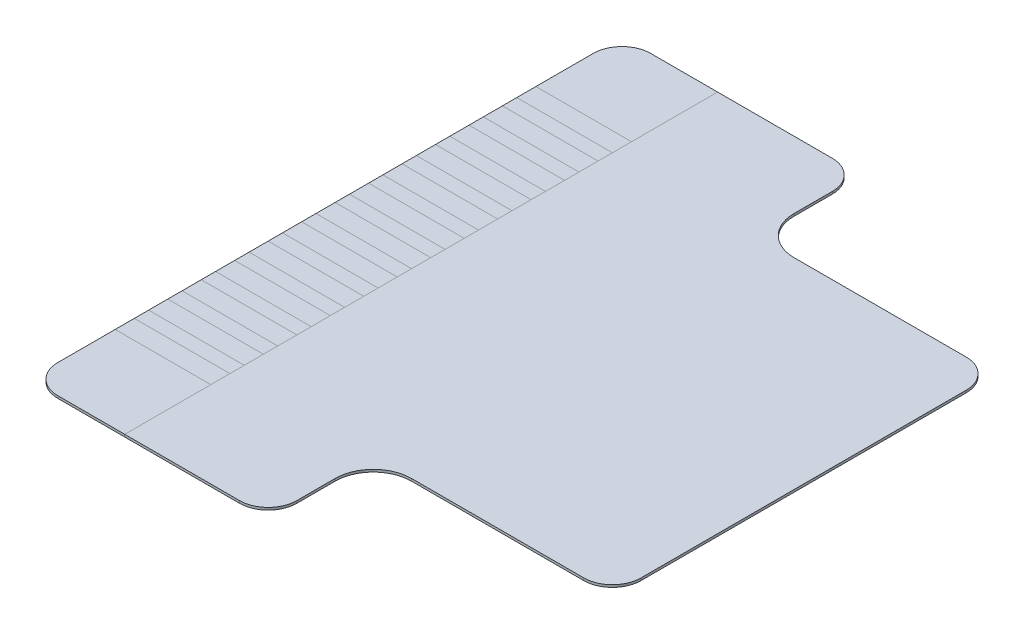
from build123d import *

# Parameters (mm, degrees)
EXTRUDE_1_DEPTH    = 0.05
SKETCH_1_3_W       = 2
SKETCH_1_3_H       = 0.4
EXTRUDE_2_DEPTH    = 0.05
EXTRUDE_2_2_DEPTH  = 0.05
EXTRUDE_2_3_DEPTH  = 0.05
EXTRUDE_2_4_DEPTH  = 0.05
EXTRUDE_2_5_DEPTH  = 0.05
EXTRUDE_2_6_DEPTH  = 0.05
EXTRUDE_2_7_DEPTH  = 0.05
EXTRUDE_2_8_DEPTH  = 0.05
EXTRUDE_2_9_DEPTH  = 0.05
EXTRUDE_2_10_DEPTH = 0.05
EXTRUDE_2_11_DEPTH = 0.05
EXTRUDE_2_12_DEPTH = 0.05
EXTRUDE_2_13_DEPTH = 0.05
SKETCH_1_5_W       = 2
SKETCH_1_5_H       = 0.3
EXTRUDE_3_DEPTH    = 0.05
EXTRUDE_3_2_DEPTH  = 0.05
EXTRUDE_3_3_DEPTH  = 0.05
EXTRUDE_3_4_DEPTH  = 0.05
EXTRUDE_3_5_DEPTH  = 0.05
EXTRUDE_3_6_DEPTH  = 0.05
EXTRUDE_3_7_DEPTH  = 0.05
EXTRUDE_3_8_DEPTH  = 0.05
EXTRUDE_3_9_DEPTH  = 0.05
EXTRUDE_3_10_DEPTH = 0.05
EXTRUDE_3_11_DEPTH = 0.05
EXTRUDE_3_12_DEPTH = 0.05
EXTRUDE_3_13_DEPTH = 0.05
EXTRUDE_3_14_DEPTH = 0.05


with BuildPart() as part:
    # 草图1 → 凸台-拉伸1 (new body)
    with BuildSketch(Plane(origin=(0, 0, 0), x_dir=(1, 0, 0), z_dir=(0, 1, 0))):
        with BuildLine():
            Line((-5.302780917, 1.2), (-5.302780917, 0.9))
            Line((-5.302780917, 0.9), (-5.302780917, 0.5))
            Line((-5.302780917, 0.5), (-5.302780917, 0.2))
            Line((-5.302780917, 0.2), (-5.302780917, -0.2))
            Line((-5.302780917, -0.2), (-5.302780917, -0.5))
            Line((-5.302780917, -0.5), (-5.302780917, -0.9))
            Line((-5.302780917, -0.9), (-5.302780917, -1.2))
            Line((-5.302780917, -1.2), (-5.302780917, -1.6))
            Line((-5.302780917, -1.6), (-5.302780917, -1.9))
            Line((-5.302780917, -1.9), (-5.302780917, -2.3))
            Line((-5.302780917, -2.3), (-5.302780917, -2.6))
            Line((-5.302780917, -2.6), (-5.302780917, -3))
            Line((-5.302780917, -3), (-5.302780917, -3.3))
            Line((-5.302780917, -3.3), (-5.302780917, -3.7))
            Line((-5.302780917, -3.7), (-5.302780917, -4))
            Line((-5.302780917, -4), (-5.302780917, -4.4))
            Line((-5.302780917, -4.4), (-5.302780917, -6.2))
            Line((-5.302780917, -6.2), (-2.902780917, -6.2))
            ThreePointArc((-2.902780917, -6.2), (-2.478516848, -6.024264069), (-2.302780917, -5.6))
            Line((-2.302780917, -5.6), (-2.302780917, -4.8))
            ThreePointArc((-2.302780917, -4.8), (-2.068466342, -4.234314575), (-1.502780917, -4))
            Line((-1.502780917, -4), (2.097219083, -4))
            ThreePointArc((2.097219083, -4), (2.521483152, -3.824264069), (2.697219083, -3.4))
            Line((2.697219083, -3.4), (2.697219083, 3.4))
            ThreePointArc((2.697219083, 3.4), (2.521483152, 3.824264069), (2.097219083, 4))
            Line((2.097219083, 4), (-1.502780917, 4))
            ThreePointArc((-1.502780917, 4), (-2.068466342, 4.234314575), (-2.302780917, 4.8))
            Line((-2.302780917, 4.8), (-2.302780917, 5.6))
            ThreePointArc((-2.302780917, 5.6), (-2.478516848, 6.024264069), (-2.902780917, 6.2))
            Line((-2.902780917, 6.2), (-5.302780917, 6.2))
            Line((-5.302780917, 6.2), (-5.302780917, 4.4))
            Line((-5.302780917, 4.4), (-5.302780917, 4))
            Line((-5.302780917, 4), (-5.302780917, 3.7))
            Line((-5.302780917, 3.7), (-5.302780917, 3.3))
            Line((-5.302780917, 3.3), (-5.302780917, 3))
            Line((-5.302780917, 3), (-5.302780917, 2.6))
            Line((-5.302780917, 2.6), (-5.302780917, 2.3))
            Line((-5.302780917, 2.3), (-5.302780917, 1.9))
            Line((-5.302780917, 1.9), (-5.302780917, 1.6))
            Line((-5.302780917, 1.6), (-5.302780917, 1.2))
        make_face()
    extrude(amount=EXTRUDE_1_DEPTH)


with BuildPart() as body_2:
    # 草图1<3> → 凸台-拉伸2 (new body)
    with BuildSketch(Plane(origin=(0, 0, 0), x_dir=(1, 0, 0), z_dir=(0, 1, 0))):
        with Locations((-6.302780917, 0.7)):
            Rectangle(SKETCH_1_3_W, SKETCH_1_3_H)
    extrude(amount=EXTRUDE_2_DEPTH)


with BuildPart() as body_3:
    # 草图1<3> → Extrude 2 2 (new body)
    with BuildSketch(Plane(origin=(0, 0, 0), x_dir=(1, 0, 0), z_dir=(0, 1, 0))):
        with Locations((-6.302780917, 1.4)):
            Rectangle(SKETCH_1_3_W, SKETCH_1_3_H)
    extrude(amount=EXTRUDE_2_2_DEPTH)


with BuildPart() as body_4:
    # 草图1<3> → Extrude 2 3 (new body)
    with BuildSketch(Plane(origin=(0, 0, 0), x_dir=(1, 0, 0), z_dir=(0, 1, 0))):
        with Locations((-6.302780917, 0)):
            Rectangle(SKETCH_1_3_W, SKETCH_1_3_H)
    extrude(amount=EXTRUDE_2_3_DEPTH)


with BuildPart() as body_5:
    # 草图1<3> → Extrude 2 4 (new body)
    with BuildSketch(Plane(origin=(0, 0, 0), x_dir=(1, 0, 0), z_dir=(0, 1, 0))):
        with Locations((-6.302780917, 2.1)):
            Rectangle(SKETCH_1_3_W, SKETCH_1_3_H)
    extrude(amount=EXTRUDE_2_4_DEPTH)


with BuildPart() as body_6:
    # 草图1<3> → Extrude 2 5 (new body)
    with BuildSketch(Plane(origin=(0, 0, 0), x_dir=(1, 0, 0), z_dir=(0, 1, 0))):
        with Locations((-6.302780917, -0.7)):
            Rectangle(SKETCH_1_3_W, SKETCH_1_3_H)
    extrude(amount=EXTRUDE_2_5_DEPTH)


with BuildPart() as body_7:
    # 草图1<3> → Extrude 2 6 (new body)
    with BuildSketch(Plane(origin=(0, 0, 0), x_dir=(1, 0, 0), z_dir=(0, 1, 0))):
        with Locations((-6.302780917, 2.8)):
            Rectangle(SKETCH_1_3_W, SKETCH_1_3_H)
    extrude(amount=EXTRUDE_2_6_DEPTH)


with BuildPart() as body_8:
    # 草图1<3> → Extrude 2 7 (new body)
    with BuildSketch(Plane(origin=(0, 0, 0), x_dir=(1, 0, 0), z_dir=(0, 1, 0))):
        with Locations((-6.302780917, -1.4)):
            Rectangle(SKETCH_1_3_W, SKETCH_1_3_H)
    extrude(amount=EXTRUDE_2_7_DEPTH)


with BuildPart() as body_9:
    # 草图1<3> → Extrude 2 8 (new body)
    with BuildSketch(Plane(origin=(0, 0, 0), x_dir=(1, 0, 0), z_dir=(0, 1, 0))):
        with Locations((-6.302780917, 3.5)):
            Rectangle(SKETCH_1_3_W, SKETCH_1_3_H)
    extrude(amount=EXTRUDE_2_8_DEPTH)


with BuildPart() as body_10:
    # 草图1<3> → Extrude 2 9 (new body)
    with BuildSketch(Plane(origin=(0, 0, 0), x_dir=(1, 0, 0), z_dir=(0, 1, 0))):
        with Locations((-6.302780917, -2.1)):
            Rectangle(SKETCH_1_3_W, SKETCH_1_3_H)
    extrude(amount=EXTRUDE_2_9_DEPTH)


with BuildPart() as body_11:
    # 草图1<3> → Extrude 2 10 (new body)
    with BuildSketch(Plane(origin=(0, 0, 0), x_dir=(1, 0, 0), z_dir=(0, 1, 0))):
        with Locations((-6.302780917, 4.2)):
            Rectangle(SKETCH_1_3_W, SKETCH_1_3_H)
    extrude(amount=EXTRUDE_2_10_DEPTH)


with BuildPart() as body_12:
    # 草图1<3> → Extrude 2 11 (new body)
    with BuildSketch(Plane(origin=(0, 0, 0), x_dir=(1, 0, 0), z_dir=(0, 1, 0))):
        with Locations((-6.302780917, -2.8)):
            Rectangle(SKETCH_1_3_W, SKETCH_1_3_H)
    extrude(amount=EXTRUDE_2_11_DEPTH)


with BuildPart() as body_13:
    # 草图1<3> → Extrude 2 12 (new body)
    with BuildSketch(Plane(origin=(0, 0, 0), x_dir=(1, 0, 0), z_dir=(0, 1, 0))):
        with Locations((-6.302780917, -3.5)):
            Rectangle(SKETCH_1_3_W, SKETCH_1_3_H)
    extrude(amount=EXTRUDE_2_12_DEPTH)


with BuildPart() as body_14:
    # 草图1<3> → Extrude 2 13 (new body)
    with BuildSketch(Plane(origin=(0, 0, 0), x_dir=(1, 0, 0), z_dir=(0, 1, 0))):
        with Locations((-6.302780917, -4.2)):
            Rectangle(SKETCH_1_3_W, SKETCH_1_3_H)
    extrude(amount=EXTRUDE_2_13_DEPTH)


with BuildPart() as body_15:
    # 草图1<5> → 凸台-拉伸3 (new body)
    with BuildSketch(Plane(origin=(0, 0, 0), x_dir=(1, 0, 0), z_dir=(0, 1, 0))):
        with Locations((-6.302780917, 1.05)):
            Rectangle(SKETCH_1_5_W, SKETCH_1_5_H)
    extrude(amount=EXTRUDE_3_DEPTH)


with BuildPart() as body_16:
    # 草图1<5> → Extrude 3 2 (new body)
    with BuildSketch(Plane(origin=(0, 0, 0), x_dir=(1, 0, 0), z_dir=(0, 1, 0))):
        with Locations((-6.302780917, 0.35)):
            Rectangle(SKETCH_1_5_W, SKETCH_1_5_H)
    extrude(amount=EXTRUDE_3_2_DEPTH)


with BuildPart() as body_17:
    # 草图1<5> → Extrude 3 3 (new body)
    with BuildSketch(Plane(origin=(0, 0, 0), x_dir=(1, 0, 0), z_dir=(0, 1, 0))):
        with Locations((-6.302780917, 1.75)):
            Rectangle(SKETCH_1_5_W, SKETCH_1_5_H)
    extrude(amount=EXTRUDE_3_3_DEPTH)


with BuildPart() as body_18:
    # 草图1<5> → Extrude 3 4 (new body)
    with BuildSketch(Plane(origin=(0, 0, 0), x_dir=(1, 0, 0), z_dir=(0, 1, 0))):
        with Locations((-6.302780917, -0.35)):
            Rectangle(SKETCH_1_5_W, SKETCH_1_5_H)
    extrude(amount=EXTRUDE_3_4_DEPTH)


with BuildPart() as body_19:
    # 草图1<5> → Extrude 3 5 (new body)
    with BuildSketch(Plane(origin=(0, 0, 0), x_dir=(1, 0, 0), z_dir=(0, 1, 0))):
        with Locations((-6.302780917, 2.45)):
            Rectangle(SKETCH_1_5_W, SKETCH_1_5_H)
    extrude(amount=EXTRUDE_3_5_DEPTH)


with BuildPart() as body_20:
    # 草图1<5> → Extrude 3 6 (new body)
    with BuildSketch(Plane(origin=(0, 0, 0), x_dir=(1, 0, 0), z_dir=(0, 1, 0))):
        with Locations((-6.302780917, -1.05)):
            Rectangle(SKETCH_1_5_W, SKETCH_1_5_H)
    extrude(amount=EXTRUDE_3_6_DEPTH)


with BuildPart() as body_21:
    # 草图1<5> → Extrude 3 7 (new body)
    with BuildSketch(Plane(origin=(0, 0, 0), x_dir=(1, 0, 0), z_dir=(0, 1, 0))):
        with Locations((-6.302780917, 3.15)):
            Rectangle(SKETCH_1_5_W, SKETCH_1_5_H)
    extrude(amount=EXTRUDE_3_7_DEPTH)


with BuildPart() as body_22:
    # 草图1<5> → Extrude 3 8 (new body)
    with BuildSketch(Plane(origin=(0, 0, 0), x_dir=(1, 0, 0), z_dir=(0, 1, 0))):
        with Locations((-6.302780917, -1.75)):
            Rectangle(SKETCH_1_5_W, SKETCH_1_5_H)
    extrude(amount=EXTRUDE_3_8_DEPTH)


with BuildPart() as body_23:
    # 草图1<5> → Extrude 3 9 (new body)
    with BuildSketch(Plane(origin=(0, 0, 0), x_dir=(1, 0, 0), z_dir=(0, 1, 0))):
        with Locations((-6.302780917, 3.85)):
            Rectangle(SKETCH_1_5_W, SKETCH_1_5_H)
    extrude(amount=EXTRUDE_3_9_DEPTH)


with BuildPart() as body_24:
    # 草图1<5> → Extrude 3 10 (new body)
    with BuildSketch(Plane(origin=(0, 0, 0), x_dir=(1, 0, 0), z_dir=(0, 1, 0))):
        with Locations((-6.302780917, -2.45)):
            Rectangle(SKETCH_1_5_W, SKETCH_1_5_H)
    extrude(amount=EXTRUDE_3_10_DEPTH)


with BuildPart() as body_25:
    # 草图1<5> → Extrude 3 11 (new body)
    with BuildSketch(Plane(origin=(0, 0, 0), x_dir=(1, 0, 0), z_dir=(0, 1, 0))):
        with BuildLine():
            Line((-7.302780917, 5.6), (-7.302780917, 4.4))
            Line((-7.302780917, 4.4), (-5.302780917, 4.4))
            Line((-5.302780917, 4.4), (-5.302780917, 6.2))
            Line((-5.302780917, 6.2), (-6.702780917, 6.2))
            ThreePointArc((-6.702780917, 6.2), (-7.127044986, 6.024264069), (-7.302780917, 5.6))
        make_face()
    extrude(amount=EXTRUDE_3_11_DEPTH)


with BuildPart() as body_26:
    # 草图1<5> → Extrude 3 12 (new body)
    with BuildSketch(Plane(origin=(0, 0, 0), x_dir=(1, 0, 0), z_dir=(0, 1, 0))):
        with Locations((-6.302780917, -3.15)):
            Rectangle(SKETCH_1_5_W, SKETCH_1_5_H)
    extrude(amount=EXTRUDE_3_12_DEPTH)


with BuildPart() as body_27:
    # 草图1<5> → Extrude 3 13 (new body)
    with BuildSketch(Plane(origin=(0, 0, 0), x_dir=(1, 0, 0), z_dir=(0, 1, 0))):
        with Locations((-6.302780917, -3.85)):
            Rectangle(SKETCH_1_5_W, SKETCH_1_5_H)
    extrude(amount=EXTRUDE_3_13_DEPTH)


with BuildPart() as body_28:
    # 草图1<5> → Extrude 3 14 (new body)
    with BuildSketch(Plane(origin=(0, 0, 0), x_dir=(1, 0, 0), z_dir=(0, 1, 0))):
        with BuildLine():
            Line((-5.302780917, -4.4), (-7.302780917, -4.4))
            Line((-7.302780917, -4.4), (-7.302780917, -5.6))
            ThreePointArc((-7.302780917, -5.6), (-7.127044986, -6.024264069), (-6.702780917, -6.2))
            Line((-6.702780917, -6.2), (-5.302780917, -6.2))
            Line((-5.302780917, -6.2), (-5.302780917, -4.4))
        make_face()
    extrude(amount=EXTRUDE_3_14_DEPTH)


solid = Compound([part.part, body_2.part, body_3.part, body_4.part, body_5.part, body_6.part, body_7.part, body_8.part, body_9.part, body_10.part, body_11.part, body_12.part, body_13.part, body_14.part, body_15.part, body_16.part, body_17.part, body_18.part, body_19.part, body_20.part, body_21.part, body_22.part, body_23.part, body_24.part, body_25.part, body_26.part, body_27.part, body_28.part])
